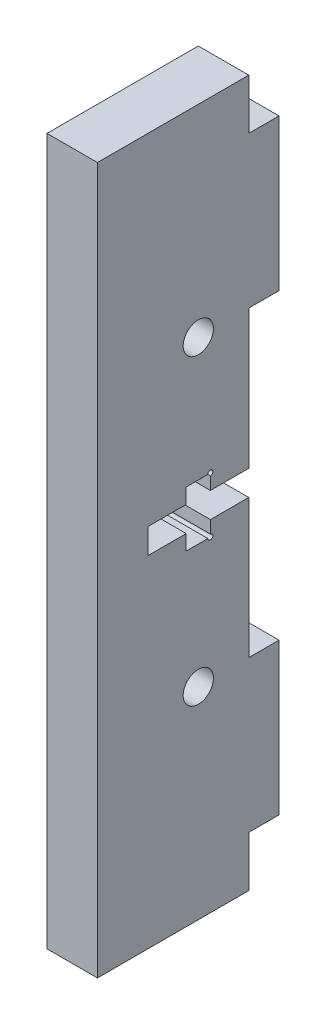
from build123d import *

# Parameters (mm, degrees)
SCHIZZO1_W                   = 15
SCHIZZO1_H                   = 70
ESTRUSIONE_ESTRUSIONE1_DEPTH = 5
SCHIZZO2_W                   = 5
SCHIZZO2_H                   = 15
ESTRUSIONE_ESTRUSIONE2_DEPTH = 3
SCHIZZO4_R                   = 1.5
TAGLIO_ESTRUSIONE2_DEPTH     = 6
SCHIZZO5_R                   = 0.25
TAGLIO_ESTRUSIONE3_DEPTH     = 10


with BuildPart() as part:
    # Schizzo1 → Estrusione-Estrusione1 (new body)
    with BuildSketch(Plane(origin=(0, 0, 0), x_dir=(0, 0, -1), z_dir=(1, 0, 0))):
        Rectangle(SCHIZZO1_W, SCHIZZO1_H)
    extrude(amount=ESTRUSIONE_ESTRUSIONE1_DEPTH)

    # Schizzo2 → Estrusione-Estrusione2 (add)
    with BuildSketch(Plane(origin=(0, 0, -7.5), x_dir=(-1, 0, 0), z_dir=(0, 0, -1))):
        with Locations((-2.5, 22.5)):
            Rectangle(SCHIZZO2_W, SCHIZZO2_H)
        with Locations((-2.5, -22.5)):
            Rectangle(SCHIZZO2_W, SCHIZZO2_H)
    extrude(amount=ESTRUSIONE_ESTRUSIONE2_DEPTH)

    # Schizzo4 → Taglio-Estrusione2 (cut, through all)
    with BuildSketch(Plane(origin=(0, 0, 0), x_dir=(0, 0, -1), z_dir=(1, 0, 0))):
        with Locations((2.5, 15)):
            Circle(SCHIZZO4_R)
        with Locations((2.5, -15)):
            Circle(SCHIZZO4_R)
        Polygon((-2.5, 1.25), (1.3, 1.25), (1.3, 2.75), (3.7, 2.75), (3.7, 1.25), (7.5, 1.25), (7.5, -1.25), (3.7, -1.25), (3.7, -2.75), (1.3, -2.75), (1.3, -1.25), (-2.5, -1.25), align=None)
    extrude(amount=TAGLIO_ESTRUSIONE2_DEPTH, mode=Mode.SUBTRACT)

    # Schizzo5 → Taglio-Estrusione3 (cut)
    with BuildSketch(Plane(origin=(5, 0, 0), x_dir=(0, 0, -1), z_dir=(1, 0, 0))):
        with Locations((3.7, 2.75)):
            Circle(SCHIZZO5_R)
        with Locations((3.7, -2.75)):
            Circle(SCHIZZO5_R)
    extrude(amount=-TAGLIO_ESTRUSIONE3_DEPTH, mode=Mode.SUBTRACT)


solid = part.part
